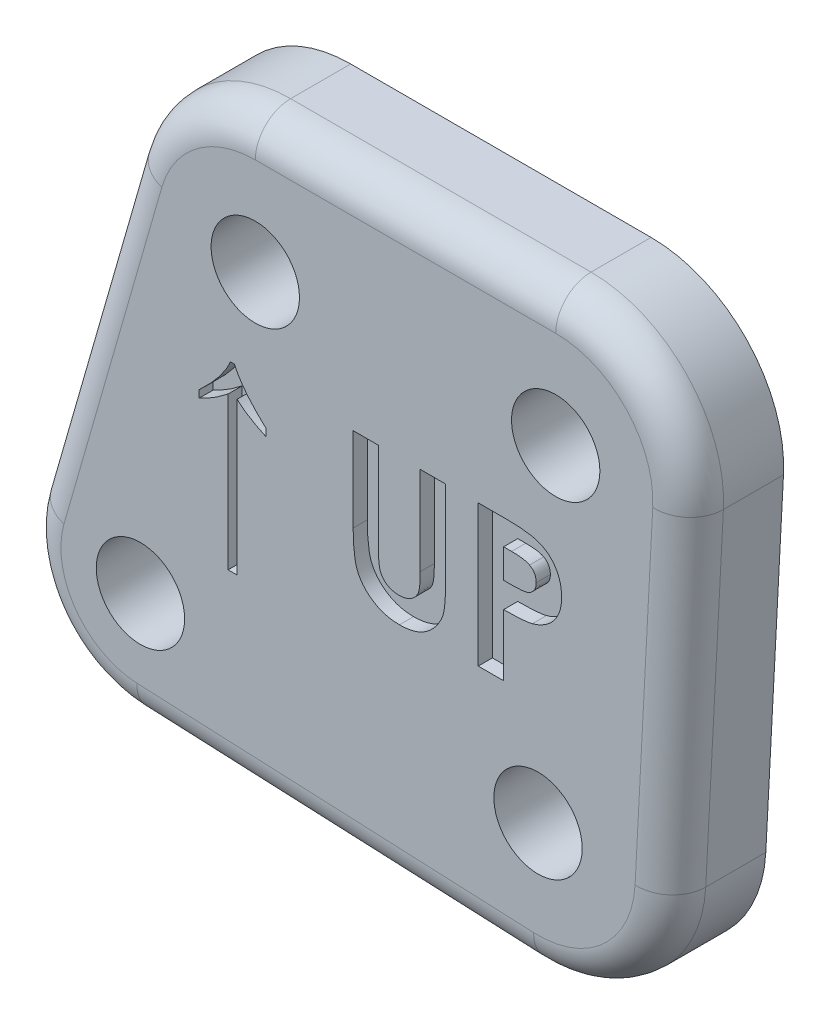
from build123d import *

# Parameters (mm, degrees)
BOSS_EXTRUDE1_DEPTH        = 3.429
F_1_8_0_1250_DOWEL_HOLE1_D = 3.175
FILLET1_R                  = 1.27
CUT_EXTRUDE1_DEPTH         = 0.508


with BuildPart() as part:
    # Sketch1 → Boss-Extrude1 (new body)
    with BuildSketch(Plane.XY):
        with BuildLine():
            Line((-4.577282168, 1.315254426), (-8.094477879, -10.925112831))
            ThreePointArc((-8.094477879, -10.925112831), (-7.478933387, -14.474180463), (-4.310944444, -16.188421442))
            Line((-4.310944444, -16.188421442), (9.948333333, -16.822793971))
            ThreePointArc((9.948333333, -16.822793971), (13.360297392, -15.591967941), (14.915917412, -12.315311443))
            Line((14.915917412, -12.315311443), (15.550917412, -0.250311443))
            ThreePointArc((15.550917412, -0.250311443), (14.249961251, 3.277903141), (10.795, 4.7625))
            Line((10.795, 4.7625), (0, 4.7625))
            ThreePointArc((0, 4.7625), (-2.865092236, 3.804293985), (-4.577282168, 1.315254426))
        make_face()
    extrude(amount=-BOSS_EXTRUDE1_DEPTH)

    # 1/8 (0.1250) Dowel Hole1 (through all)
    with Locations(Plane.XY):
        with Locations((0, 0), (10.795, 0), (10.16, -12.065), (-4.1275, -12.065)):
            Hole(F_1_8_0_1250_DOWEL_HOLE1_D / 2)

    # Fillet1
    fillet1_edges = [part.edges().sort_by_distance(p)[0] for p in [
        (-7.478933387, -14.474180463, 0),
        (2.818694444, -16.505607706, 0),
        (13.360297392, -15.591967941, 0),
        (15.233417412, -6.282811443, 0),
        (14.249961251, 3.277903141, 0),
        (5.3975, 4.7625, 0),
        (-2.865092236, 3.804293985, 0),
        (-6.335880023, -4.804929203, 0),
    ]]
    fillet(fillet1_edges, radius=FILLET1_R)

    # Sketch4 → Cut-Extrude1 (cut)
    with BuildSketch(Plane.XY):
        with BuildLine():
            add(Edge.make_bspline(
                [(-2.018974359, -4.668878205), (-1.948566486, -4.602596144), (-1.811954509, -4.473989456), (-1.622650436, -4.278725008), (-1.451242121, -4.091223483), (-1.300759226, -3.909816539), (-1.170264987, -3.734034922), (-1.060781203, -3.564637469), (-0.968735298, -3.402245082), (-0.92205791, -3.292816631), (-0.899583333, -3.240128205)],
                knots=[0, 0, 0, 0, 0.00029006, 0.000562801, 0.000815667, 0.001052022, 0.001269597, 0.001471982, 0.001656914, 0.00182864, 0.00182864, 0.00182864, 0.00182864], degree=3))
            Line((-0.899583333, -3.240128205), (-0.751009615, -3.240128205))
            add(Edge.make_bspline(
                [(-0.751009615, -3.240128205), (-0.724803836, -3.296246809), (-0.670789648, -3.411915984), (-0.568911154, -3.58116763), (-0.453367348, -3.755971821), (-0.318160102, -3.932601391), (-0.16632453, -4.112875867), (0.003433176, -4.295906045), (0.189298028, -4.483449202), (0.32242269, -4.605973777), (0.390769231, -4.668878205)],
                knots=[0, 0, 0, 0, 0.000185689, 0.000382733, 0.000591872, 0.000814126, 0.00104957, 0.001298745, 0.001562829, 0.001841461, 0.001841461, 0.001841461, 0.001841461], degree=3))
            Line((0.390769231, -4.668878205), (0.390769231, -4.933461538))
            add(Edge.make_bspline(
                [(0.390769231, -4.933461538), (0.334255893, -4.907423106), (0.224138151, -4.856686528), (0.066548797, -4.775515184), (-0.081259468, -4.69625071), (-0.216643198, -4.613897697), (-0.342282541, -4.533613252), (-0.455166896, -4.450225285), (-0.558928956, -4.368736527), (-0.621134402, -4.310435078), (-0.651282051, -4.282179487)],
                knots=[0, 0, 0, 0, 0.000186645, 0.000363683, 0.000531718, 0.000689661, 0.000838975, 0.000978809, 0.001110559, 0.00123446, 0.00123446, 0.00123446, 0.00123446], degree=3))
            Line((-0.651282051, -4.282179487), (-0.651282051, -9.752948718))
            Line((-0.651282051, -9.752948718), (-0.976923077, -9.752948718))
            Line((-0.976923077, -9.752948718), (-0.976923077, -4.282179487))
            add(Edge.make_bspline(
                [(-0.976923077, -4.282179487), (-1.056589941, -4.344226035), (-1.216515582, -4.468780127), (-1.471133749, -4.63872642), (-1.738746443, -4.794848927), (-1.925127206, -4.887040757), (-2.018974359, -4.933461538)],
                knots=[0, 0, 0, 0, 0.000302852, 0.000607954, 0.000917584, 0.001231609, 0.001231609, 0.001231609, 0.001231609], degree=3))
            Line((-2.018974359, -4.933461538), (-2.018974359, -4.668878205))
        make_face()
        with BuildLine():
            Line((3.516923077, -3.175), (4.428717949, -3.175))
            Line((4.428717949, -3.175), (4.428717949, -6.48025641))
            add(Edge.make_bspline(
                [(4.428717949, -6.48025641), (4.428767528, -6.514523875), (4.428863289, -6.580711129), (4.433657142, -6.675668169), (4.438043848, -6.762953571), (4.445958711, -6.842471776), (4.457651676, -6.914256798), (4.468974282, -6.97876976), (4.48429831, -7.034855629), (4.507327873, -7.098696032), (4.54280887, -7.170424212), (4.600782851, -7.245180966), (4.667679865, -7.313407355), (4.74785979, -7.370196416), (4.837974934, -7.416133648), (4.937530156, -7.450168053), (5.046385117, -7.469086663), (5.121652352, -7.471974936), (5.160392628, -7.473461538)],
                knots=[0, 0, 0, 0, 0.000102785, 0.000198529, 0.000285177, 0.000364968, 0.000438082, 0.000503345, 0.000561359, 0.00061222, 0.000706881, 0.000799893, 0.000894876, 0.00099259, 0.00109317, 0.001197436, 0.001307024, 0.001423252, 0.001423252, 0.001423252, 0.001423252], degree=3))
            add(Edge.make_bspline(
                [(5.160392628, -7.473461538), (5.201549391, -7.472260554), (5.281798111, -7.469918839), (5.39722312, -7.446932364), (5.504165045, -7.410330024), (5.600359561, -7.358089157), (5.685710939, -7.295469322), (5.757959093, -7.224063088), (5.81497707, -7.143728033), (5.852139266, -7.069612827), (5.873004009, -7.001396235), (5.888643173, -6.940447298), (5.900108411, -6.868533586), (5.910510051, -6.786778186), (5.916760636, -6.694334269), (5.923538376, -6.591945282), (5.92602248, -6.478910652), (5.926445878, -6.400202517), (5.926666667, -6.359158654)],
                knots=[0, 0, 0, 0, 0.000123339, 0.00024049, 0.000351523, 0.000461248, 0.000567492, 0.000668232, 0.000764525, 0.00086192, 0.000915343, 0.00097828, 0.001050553, 0.001133607, 0.00122547, 0.001328432, 0.00144143, 0.001564567, 0.001564567, 0.001564567, 0.001564567], degree=3))
            Line((5.926666667, -6.359158654), (5.926666667, -3.175))
            Line((5.926666667, -3.175), (6.838461538, -3.175))
            Line((6.838461538, -3.175), (6.838461538, -6.205496795))
            add(Edge.make_bspline(
                [(6.838461538, -6.205496795), (6.838334919, -6.266894515), (6.838091443, -6.384956343), (6.834352377, -6.554619498), (6.826392582, -6.709579576), (6.819707273, -6.849881853), (6.80676891, -6.975337322), (6.793290171, -7.086481711), (6.776110358, -7.182921152), (6.750547831, -7.292705734), (6.706434475, -7.41911866), (6.635317962, -7.564677665), (6.545040153, -7.707188748), (6.438336293, -7.845084188), (6.317857875, -7.973184608), (6.186276164, -8.085640195), (6.045681664, -8.180765496), (5.894605265, -8.256234581), (5.733175541, -8.315094779), (5.559795264, -8.354645867), (5.374582667, -8.381367078), (5.246652825, -8.383933979), (5.180745192, -8.38525641)],
                knots=[0, 0, 0, 0, 0.000184194, 0.000354186, 0.00050903, 0.000649698, 0.000775461, 0.000887293, 0.000985504, 0.001069178, 0.001225261, 0.00138592, 0.001554196, 0.001730469, 0.001908274, 0.002080795, 0.002248728, 0.002416204, 0.002586176, 0.002762906, 0.002948846, 0.003146433, 0.003146433, 0.003146433, 0.003146433], degree=3))
            add(Edge.make_bspline(
                [(5.180745192, -8.38525641), (5.13695485, -8.38451882), (5.050557403, -8.383063569), (4.923494801, -8.370232057), (4.800663835, -8.351323234), (4.682295306, -8.323737208), (4.567978377, -8.288101215), (4.457743421, -8.24423579), (4.352000096, -8.192385607), (4.251340127, -8.133027578), (4.155887386, -8.068842087), (4.068648508, -7.997689768), (3.986621399, -7.924832604), (3.912175786, -7.847204457), (3.844752518, -7.765620289), (3.784490453, -7.679895204), (3.73147912, -7.590036816), (3.684385048, -7.494425434), (3.644077119, -7.388201475), (3.61009602, -7.267586511), (3.580409333, -7.130690021), (3.558347938, -6.977203585), (3.538346948, -6.807633078), (3.525687425, -6.621536742), (3.519064658, -6.418909238), (3.517654975, -6.278431791), (3.516923077, -6.205496795)],
                knots=[0, 0, 0, 0, 0.000131337, 0.000259125, 0.000382762, 0.000503962, 0.000623372, 0.000741667, 0.000859541, 0.000976302, 0.001092026, 0.001204228, 0.001313754, 0.001420992, 0.001526532, 0.001630991, 0.001735009, 0.00183923, 0.001950356, 0.002075322, 0.002214841, 0.002370275, 0.002540304, 0.002726999, 0.002929633, 0.003148444, 0.003148444, 0.003148444, 0.003148444], degree=3))
            Line((3.516923077, -6.205496795), (3.516923077, -3.175))
        make_face()
        with BuildLine():
            Line((8.010769231, -3.175), (9.028397436, -3.175))
            add(Edge.make_bspline(
                [(9.028397436, -3.175), (9.094887943, -3.175297626), (9.223162068, -3.175871808), (9.408143909, -3.182834532), (9.578798715, -3.195312157), (9.735087278, -3.210732529), (9.876945336, -3.232351291), (10.004550537, -3.257135508), (10.117929363, -3.287329898), (10.218360329, -3.32317022), (10.308493877, -3.365424559), (10.393789284, -3.410428447), (10.472318864, -3.464139), (10.548046244, -3.520767523), (10.616641957, -3.585723716), (10.682385415, -3.654684651), (10.742492203, -3.730385263), (10.797240835, -3.811909214), (10.846906279, -3.897750292), (10.890297334, -3.988061954), (10.925493728, -4.082987109), (10.955019126, -4.181911701), (10.978734214, -4.284831416), (10.994519731, -4.392379221), (11.005242048, -4.503804176), (11.006188144, -4.579640071), (11.006666667, -4.617996795)],
                knots=[0, 0, 0, 0, 0.000199466, 0.000384811, 0.000555193, 0.000712751, 0.000855807, 0.000985529, 0.001102539, 0.001207478, 0.001304921, 0.001400999, 0.001496396, 0.001590023, 0.001684356, 0.001779383, 0.001875693, 0.001973914, 0.002073755, 0.002172983, 0.002274103, 0.00237713, 0.002482542, 0.002590626, 0.002703027, 0.002818059, 0.002818059, 0.002818059, 0.002818059], degree=3))
            add(Edge.make_bspline(
                [(11.006666667, -4.617996795), (11.005974305, -4.660429925), (11.004613729, -4.74381624), (10.991275701, -4.866050348), (10.968490135, -4.982589502), (10.938710592, -5.094416499), (10.897185137, -5.199691537), (10.849744254, -5.300926511), (10.791376921, -5.395283101), (10.724682912, -5.483941597), (10.651845445, -5.567622832), (10.571135362, -5.643910671), (10.484091033, -5.713325164), (10.391216324, -5.77659378), (10.292162558, -5.833588893), (10.187001205, -5.884844202), (10.075014166, -5.928720402), (9.997029761, -5.951667299), (9.957491987, -5.963301282)],
                knots=[0, 0, 0, 0, 0.000127269, 0.000250099, 0.000368249, 0.000483295, 0.000596686, 0.00070729, 0.00081829, 0.000928805, 0.001039852, 0.001150704, 0.001261476, 0.001373531, 0.001487509, 0.001604022, 0.00172421, 0.001847809, 0.001847809, 0.001847809, 0.001847809], degree=3))
            add(Edge.make_bspline(
                [(9.957491987, -5.963301282), (9.931450135, -5.969780537), (9.875035098, -5.98381669), (9.781683706, -5.998066908), (9.674106028, -6.011169107), (9.551954195, -6.022428861), (9.415157784, -6.03008287), (9.26384925, -6.03606031), (9.097960021, -6.040406527), (8.982607212, -6.04056075), (8.922564103, -6.040641026)],
                knots=[0, 0, 0, 0, 8.047e-05, 0.000174324, 0.000283, 0.000405628, 0.000542233, 0.000693982, 0.000859906, 0.001040029, 0.001040029, 0.001040029, 0.001040029], degree=3))
            Line((8.922564103, -6.040641026), (8.922564103, -8.255))
            Line((8.922564103, -8.255), (8.010769231, -8.255))
            Line((8.010769231, -8.255), (8.010769231, -3.175))
        make_face()
        with BuildLine():
            Line((8.922564103, -5.128846154), (9.245152244, -5.128846154))
            add(Edge.make_bspline(
                [(9.245152244, -5.128846154), (9.303852249, -5.12847395), (9.41186113, -5.12778909), (9.559363121, -5.117885614), (9.677898558, -5.102761006), (9.771543755, -5.081068821), (9.845485507, -5.048148057), (9.909255639, -5.010064933), (9.96395291, -4.961909867), (10.011312695, -4.906884465), (10.049175417, -4.843657521), (10.075431242, -4.773258562), (10.09248651, -4.697166745), (10.094061722, -4.644211877), (10.094871795, -4.616979167)],
                knots=[0, 0, 0, 0, 0.000176076, 0.000323983, 0.000443145, 0.000534466, 0.000611032, 0.000685032, 0.000756448, 0.000828635, 0.000902109, 0.000976193, 0.001053238, 0.001134807, 0.001134807, 0.001134807, 0.001134807], degree=3))
            add(Edge.make_bspline(
                [(10.094871795, -4.616979167), (10.094070055, -4.593186302), (10.092514486, -4.547022425), (10.081086855, -4.480396499), (10.062874498, -4.418287391), (10.036485492, -4.36134375), (10.002370757, -4.309662332), (9.960777991, -4.263263494), (9.912240911, -4.221153568), (9.874767448, -4.198864141), (9.855729167, -4.187540064)],
                knots=[0, 0, 0, 0, 7.135e-05, 0.000138437, 0.000202183, 0.000265012, 0.000325977, 0.000387246, 0.000451486, 0.000517827, 0.000517827, 0.000517827, 0.000517827], degree=3))
            add(Edge.make_bspline(
                [(9.855729167, -4.187540064), (9.839602644, -4.179384419), (9.805459489, -4.162117247), (9.747310388, -4.142042897), (9.680207212, -4.125107971), (9.603696941, -4.111052146), (9.518084796, -4.100143366), (9.42338605, -4.091800879), (9.319461348, -4.08844604), (9.247187935, -4.087360442), (9.209535256, -4.086794872)],
                knots=[0, 0, 0, 0, 5.4164e-05, 0.000114677, 0.000184032, 0.000261673, 0.000347883, 0.000442872, 0.00054675, 0.000659725, 0.000659725, 0.000659725, 0.000659725], degree=3))
            Line((9.209535256, -4.086794872), (8.922564103, -4.086794872))
            Line((8.922564103, -4.086794872), (8.922564103, -5.128846154))
        make_face(mode=Mode.SUBTRACT)
    extrude(amount=-CUT_EXTRUDE1_DEPTH, mode=Mode.SUBTRACT)


solid = part.part
